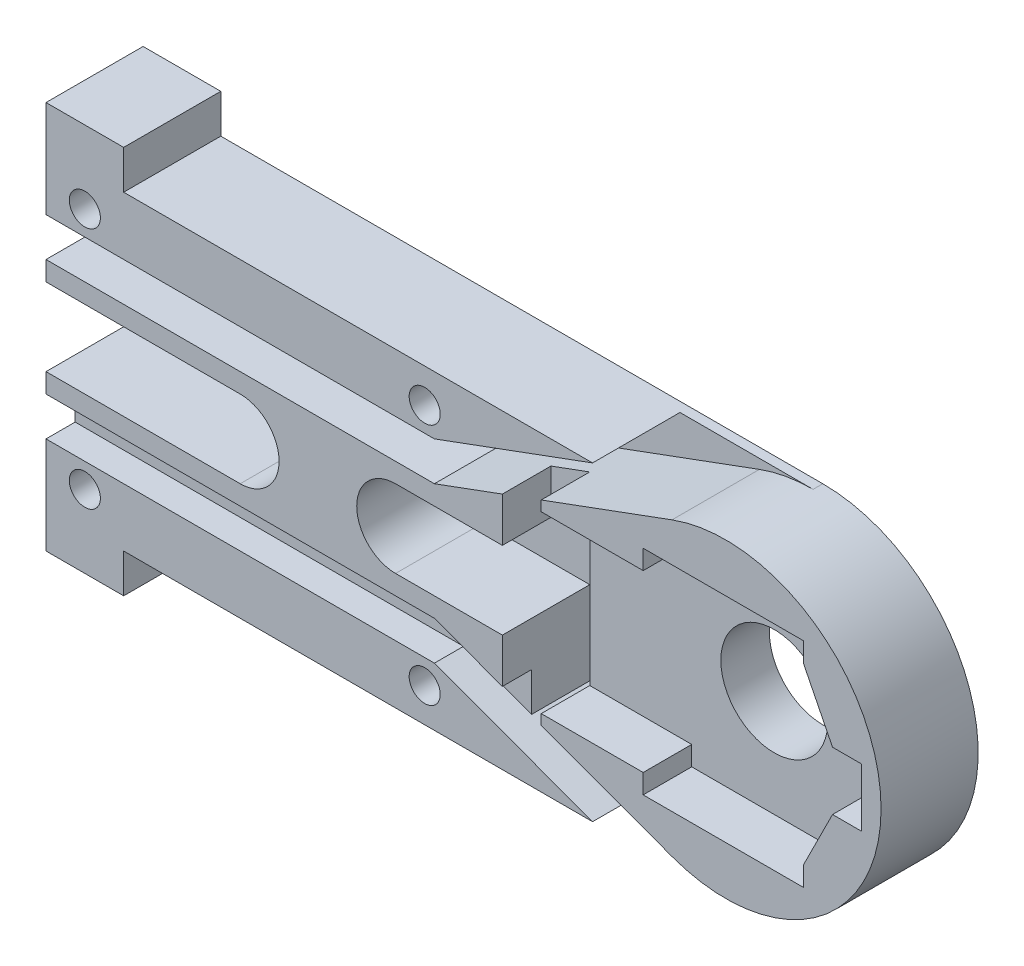
from build123d import *

# Parameters (mm, degrees)
BOSS_EXTRUDE1_DEPTH              = 5
SKETCH4_R                        = 2.75
POT_HOLE_DEPTH                   = 82.062316455
POT_START                        = 5
POT_INSERT_DEPTH                 = 2.5
MIDDLE_START                     = 3.5
MIDDLE_FLEXION_DEPTH             = 2.5
MIDDLE_START_2                   = 0.5
MIDDLE_EXTENSION_DEPTH           = 5.5
PROXIMAL_START                   = 0.5
PROXIMAL_FLEXION_EXTENSION_DEPTH = 5.5
SKETCH9_R                        = 0.8
SCREW_HOLES_DEPTH                = 82.062316455
CUT_EXTRUDE4_START               = 0.5
CUT_EXTRUDE4_DEPTH               = 5.5
CUT_EXTRUDE5_START               = 5
CUT_EXTRUDE5_DEPTH               = 2.5


with BuildPart() as part:
    # Sketch1 → Boss-Extrude1 (new body)
    with BuildSketch(Plane.XY):
        with BuildLine():
            Line((72.287602711, 8), (41.287602711, 8))
            Line((41.287602711, 8), (41.287602711, 10))
            Line((41.287602711, 10), (37.287602711, 10))
            Line((37.287602711, 10), (37.287602711, -10))
            Line((37.287602711, -10), (41.287602711, -10))
            Line((41.287602711, -10), (41.287602711, -8))
            Line((41.287602711, -8), (72.287602711, -8))
            ThreePointArc((72.287602711, -8), (80.287602711, 0), (72.287602711, 8))
        make_face()
    extrude(amount=BOSS_EXTRUDE1_DEPTH)

    # Sketch4 → Pot Hole (cut, through all)
    with BuildSketch(Plane.XY):
        with Locations((72.287602711, 0)):
            Circle(SKETCH4_R)
    extrude(amount=POT_HOLE_DEPTH, mode=Mode.SUBTRACT)

    # Sketch3 → Pot Insert (cut)
    with BuildSketch(Plane(origin=(28.28760271, 0, 0), x_dir=(1, 0, 0), z_dir=(0, 0, 1)).offset(POT_START)):
        Polygon((51.000000001, 0), (51.000000001, 1.5), (49.500000001, 1.5), (48.000000001, 4.5), (48.000000001, 5.5), (44.000000001, 5.5), (39.750000001, 5.5), (39.750000001, 4.5), (34.500000001, 4.5), (34.500000001, 0), (34.500000001, -4.5), (39.750000001, -4.5), (39.750000001, -5.5), (44.000000001, -5.5), (48.000000001, -5.5), (48.000000001, -4.5), (49.500000001, -1.5), (51.000000001, -1.5), align=None)
    extrude(amount=-POT_INSERT_DEPTH, mode=Mode.SUBTRACT)

    # Sketch16 → Middle Flexion (cut)
    with BuildSketch(Plane.XY.offset(MIDDLE_START)):
        with BuildLine():
            Line((65.431633901, -8), (72.287602711, -8))
            ThreePointArc((72.287602711, -8), (70.883144469, -7.875753744), (69.522310897, -7.506874262))
            Line((69.522310897, -7.506874262), (57.287602711, -3))
            Line((57.287602711, -3), (37.287602711, -3))
            Line((37.287602711, -3), (37.287602711, -5))
            Line((37.287602711, -5), (57.287602711, -5))
            Line((57.287602711, -5), (65.431633901, -8))
        make_face()
    extrude(amount=MIDDLE_FLEXION_DEPTH, mode=Mode.SUBTRACT)

    # Sketch11 → Middle Extension (cut)
    with BuildSketch(Plane.XY.offset(MIDDLE_START_2)):
        with BuildLine():
            Line((57.287602711, 5.000000001), (37.287602711, 5.000000001))
            Line((37.287602711, 5.000000001), (37.287602711, 3.000000001))
            Line((37.287602711, 3.000000001), (57.287602711, 3.000000001))
            Line((57.287602711, 3.000000001), (69.522310897, 7.506874262))
            ThreePointArc((69.522310897, 7.506874262), (70.88314447, 7.875753745), (72.287602711, 8))
            Line((72.287602711, 8), (65.4316339, 8))
            Line((65.4316339, 8), (57.287602711, 5.000000001))
        make_face()
    extrude(amount=MIDDLE_EXTENSION_DEPTH, mode=Mode.SUBTRACT)

    # Sketch8 → Proximal Flexion/Extension (cut)
    with BuildSketch(Plane.XY.offset(PROXIMAL_START)):
        with BuildLine():
            ThreePointArc((47.287602711, 2), (49.287602711, 0), (47.287602711, -2))
            Line((47.287602711, -2), (37.287602711, -2))
            Line((37.287602711, -2), (37.287602711, 0))
            Line((37.287602711, 0), (37.287602711, 2))
            Line((37.287602711, 2), (47.287602711, 2))
        make_face()
    extrude(amount=PROXIMAL_FLEXION_EXTENSION_DEPTH, mode=Mode.SUBTRACT)

    # Sketch9 → Screw Holes (cut, through all)
    with BuildSketch(Plane.XY):
        with Locations((47.287602711, 0)):
            Circle(SKETCH9_R)
        with Locations((56.787602711, -6.25)):
            Circle(SKETCH9_R)
        with Locations((39.287602711, -6.25)):
            Circle(SKETCH9_R)
        with Locations((55.287602711, 0)):
            Circle(SKETCH9_R)
        with Locations((39.287602711, 6.25)):
            Circle(SKETCH9_R)
        with Locations((56.787602711, 6.25)):
            Circle(SKETCH9_R)
    extrude(amount=SCREW_HOLES_DEPTH, mode=Mode.SUBTRACT)

    # Sketch12 → Cut-Extrude4 (cut)
    with BuildSketch(Plane.XY.offset(CUT_EXTRUDE4_START)):
        with BuildLine():
            Line((62.787602711, 2), (60.787602711, 2))
            Line((60.787602711, 2), (55.287602711, 2))
            ThreePointArc((55.287602711, 2), (53.287602711, 0), (55.287602711, -2))
            Line((55.287602711, -2), (60.787602711, -2))
            Line((60.787602711, -2), (60.787602711, -6.289287793))
            Line((60.787602711, -6.289287793), (65.431633901, -8))
            Line((65.431633901, -8), (72.287602711, -8))
            ThreePointArc((72.287602711, -8), (70.883144469, -7.875753745), (69.522310897, -7.506874262))
            Line((69.522310897, -7.506874262), (62.787602711, -5.026023675))
            Line((62.787602711, -5.026023675), (62.787602711, 2))
        make_face()
    extrude(amount=CUT_EXTRUDE4_DEPTH, mode=Mode.SUBTRACT)

    # Sketch13 → Cut-Extrude5 (cut)
    with BuildSketch(Plane.XY.offset(CUT_EXTRUDE5_START)):
        Polygon((62.787602711, 2), (60.787602711, 2), (60.787602711, 4.289287794), (62.787602711, 5.026023675), align=None)
    extrude(amount=-CUT_EXTRUDE5_DEPTH, mode=Mode.SUBTRACT)


solid = part.part
